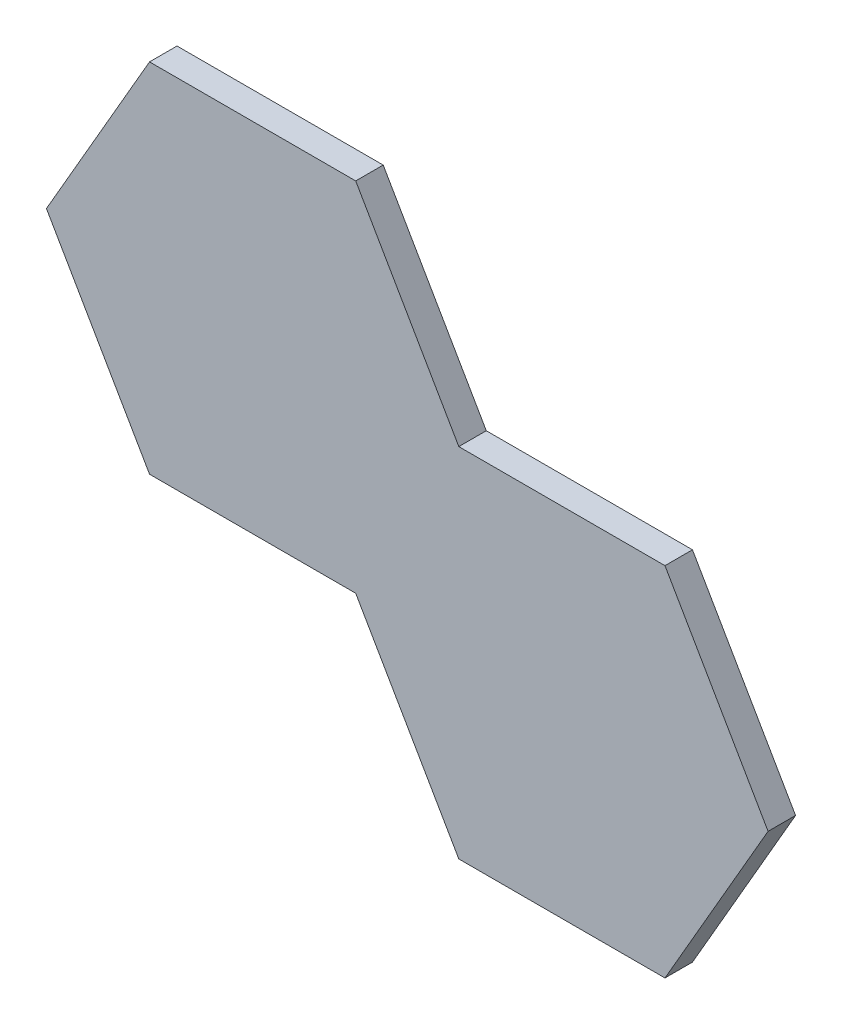
from build123d import *

# Parameters (mm, degrees)
SKETCH1_R           = 5
BOSS_EXTRUDE1_DEPTH = 4
BOSS_EXTRUDE2_DEPTH = 8
SKETCH1_5_R         = 5
BOSS_EXTRUDE3_DEPTH = 2


with BuildPart() as part:
    # Sketch1 → Boss-Extrude1 (new body)
    with BuildSketch(Plane.XY):
        Polygon((-30, 0), (-15, -25.980762114), (15, -25.980762114), (30, 0), (15, 25.980762114), (-15, 25.980762114), align=None)
        Polygon((5, -8.660254038), (-5, -8.660254038), (-10, 0), (-5, 8.660254038), (5, 8.660254038), (10, 0), align=None, mode=Mode.SUBTRACT)
        with Locations((-20, 0)):
            Circle(SKETCH1_R, mode=Mode.SUBTRACT)
        with Locations((20, 0)):
            Circle(SKETCH1_R, mode=Mode.SUBTRACT)
    extrude(amount=-BOSS_EXTRUDE1_DEPTH)

    # Sketch1_4 → Boss-Extrude2 (add)
    with BuildSketch(Plane.XY):
        Polygon((-10, 0), (-5, -8.660254038), (5, -8.660254038), (10, 0), (5, 8.660254038), (-5, 8.660254038), align=None)
    extrude(amount=-BOSS_EXTRUDE2_DEPTH)

    # Sketch1_5 → Boss-Extrude3 (add)
    with BuildSketch(Plane.XY):
        with Locations((-20, 0)):
            Circle(SKETCH1_5_R)
        with Locations((20, 0)):
            Circle(SKETCH1_5_R)
    extrude(amount=-BOSS_EXTRUDE3_DEPTH)

    # Mirror1: part across plane


with BuildPart() as part_1:
    add(part.part)
    add(part.part.mirror(Plane(origin=(22.5, -12.990381057, -4), x_dir=(0, 0, 1), z_dir=(0.8660254037844386, -0.5000000000000003, 0))))


solid = part_1.part
